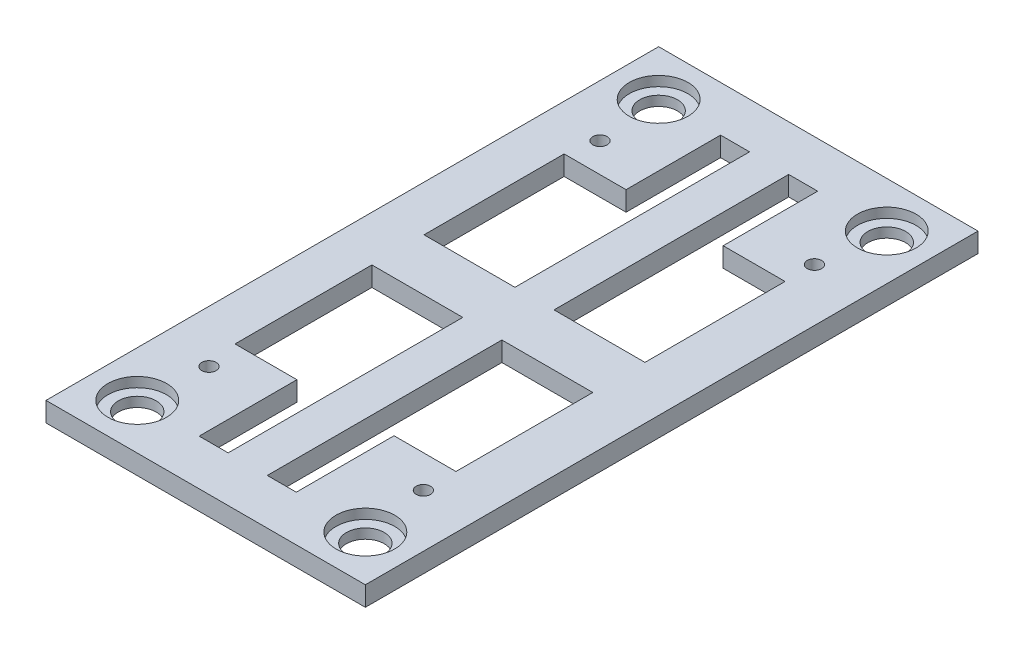
from build123d import *

# Parameters (mm, degrees)
SKETCH_1_R          = 2.9
SKETCH_1_R_2        = 1.1
EXTRUDE_1_DEPTH     = 3
SKETCH_2_R          = 4.5
CUT_EXTRUDE_1_DEPTH = 1.5


with BuildPart() as part:
    # 草图1 → 凸台-拉伸1 (new body)
    with BuildSketch(Plane(origin=(0, 0, 0), x_dir=(1, 0, 0), z_dir=(0, 1, 0))):
        Polygon((-42, 47), (-42, 0), (-42, -47), (0, -47), (7, -47), (7, 47), (0, 47), align=None)
        with Locations((-35, -40)):
            Circle(SKETCH_1_R, mode=Mode.SUBTRACT)
        with Locations((-34, -30)):
            Circle(SKETCH_1_R_2, mode=Mode.SUBTRACT)
        Polygon((-35, -25), (-35, -4), (-21.05, -4), (-21.05, -40), (-25.5, -40), (-25.5, -25), align=None, mode=Mode.SUBTRACT)
        with Locations((0, -40)):
            Circle(SKETCH_1_R, mode=Mode.SUBTRACT)
        with Locations((-1.1, -30)):
            Circle(SKETCH_1_R_2, mode=Mode.SUBTRACT)
        Polygon((-1.1, -4), (-1.1, -25), (-10.6, -25), (-10.6, -40), (-15.05, -40), (-15.05, -4), align=None, mode=Mode.SUBTRACT)
        Polygon((-21.05, 4), (-35, 4), (-35, 25.5), (-25.5, 25.5), (-25.5, 40), (-21.05, 40), align=None, mode=Mode.SUBTRACT)
        with Locations((-34, 30)):
            Circle(SKETCH_1_R_2, mode=Mode.SUBTRACT)
        with Locations((-35, 40)):
            Circle(SKETCH_1_R, mode=Mode.SUBTRACT)
        Polygon((-10.6, 25.5), (-1.1, 25.5), (-1.1, 4), (-15.05, 4), (-15.05, 40), (-10.6, 40), align=None, mode=Mode.SUBTRACT)
        with Locations((-1.1, 30)):
            Circle(SKETCH_1_R_2, mode=Mode.SUBTRACT)
        with Locations((0, 40)):
            Circle(SKETCH_1_R, mode=Mode.SUBTRACT)
    extrude(amount=EXTRUDE_1_DEPTH)

    # 草图2 → 切除-拉伸1 (cut)
    with BuildSketch(Plane(origin=(0, 3, 0), x_dir=(1, 0, 0), z_dir=(0, 1, 0))):
        with Locations((-35, 40)):
            Circle(SKETCH_2_R)
        with Locations((0, 40)):
            Circle(SKETCH_2_R)
        with Locations((0, -40)):
            Circle(SKETCH_2_R)
        with Locations((-35, -40)):
            Circle(SKETCH_2_R)
    extrude(amount=-CUT_EXTRUDE_1_DEPTH, mode=Mode.SUBTRACT)


solid = part.part
